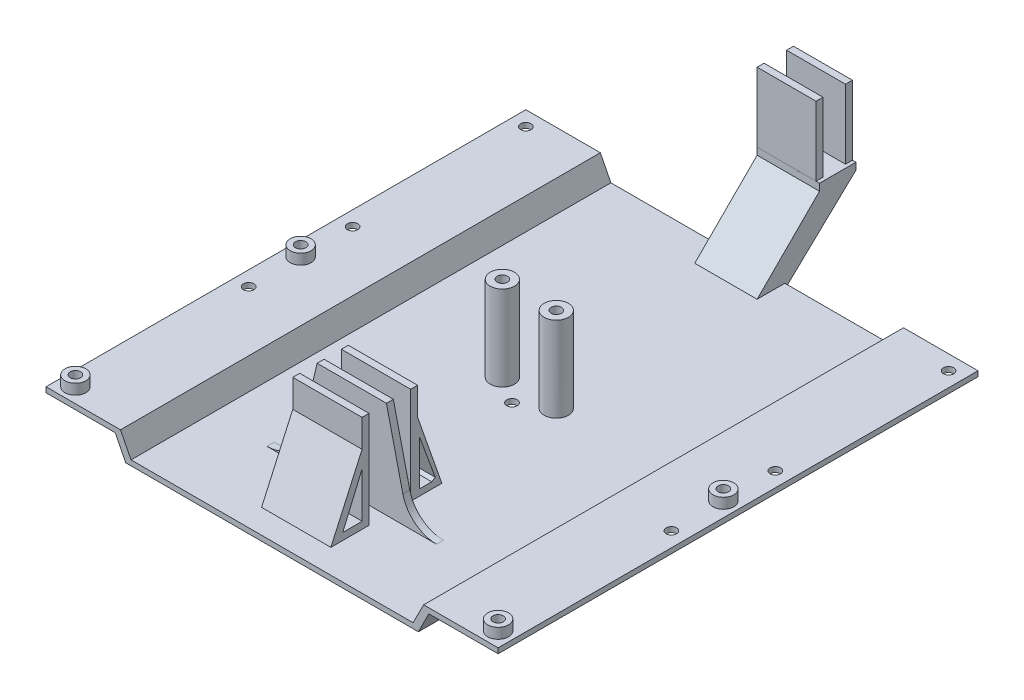
from build123d import *

# Parameters (mm, degrees)
SKETCH1_W              = 130.485281374
SKETCH1_H              = 138.485281374
SKETCH1_R              = 1.5
BOSS_EXTRUDE1_DEPTH    = 1.5
CUT_EXTRUDE1_DEPTH     = 17.5
BOSS_EXTRUDE2_DEPTH    = 138.485281
SKETCH14_R             = 3
SKETCH14_R_2           = 1.5
BOSS_EXTRUDE7_DEPTH    = 3
SKETCH15_R             = 1.5
CUT_EXTRUDE6_DEPTH     = 3
SKETCH16_R             = 3
SKETCH16_R_2           = 1.5
BOSS_EXTRUDE8_DEPTH    = 3
SKETCH17_R             = 1.5
CUT_EXTRUDE7_DEPTH     = 3
SKETCH18_R             = 3.5
SKETCH18_R_2           = 1.5
BOSS_EXTRUDE9_DEPTH    = 24.5
SKETCH19_W             = 20
SKETCH19_H             = 2
BOSS_EXTRUDE10_DEPTH   = 28
BOSS_EXTRUDE11_DEPTH   = 20
SKETCH24_R             = 1.5
CUT_EXTRUDE9_DEPTH     = 16
BOSS_EXTRUDE13_DEPTH   = 40
SKETCH27_W             = 17
SKETCH27_H             = 2
BOSS_EXTRUDE13_2_DEPTH = 40
SKETCH28_W             = 29.536458096
SKETCH28_H             = 15.843310856
CUT_EXTRUDE10_DEPTH    = 20
BOSS_EXTRUDE14_DEPTH   = 18
CUT_EXTRUDE11_DEPTH    = 26
BOSS_EXTRUDE15_DEPTH   = 2
FILLET1_R              = 10
SKETCH33_W             = 20
SKETCH33_H             = 2
BOSS_EXTRUDE16_DEPTH   = 28
BOSS_EXTRUDE17_DEPTH   = 20
CUT_EXTRUDE12_DEPTH    = 20


with BuildPart() as part:
    # Sketch1 → Boss-Extrude1 (new body)
    with BuildSketch(Plane(origin=(0, 0, 0), x_dir=(1, 0, 0), z_dir=(0, 1, 0))):
        with Locations((61, -65)):
            Rectangle(SKETCH1_W, SKETCH1_H)
        Circle(SKETCH1_R, mode=Mode.SUBTRACT)
        with Locations((122, 0)):
            Circle(SKETCH1_R, mode=Mode.SUBTRACT)
        with Locations((0, -130)):
            Circle(SKETCH1_R, mode=Mode.SUBTRACT)
        with Locations((122, -130)):
            Circle(SKETCH1_R, mode=Mode.SUBTRACT)
    extrude(amount=BOSS_EXTRUDE1_DEPTH)

    # Sketch3 → Cut-Extrude1 (cut)
    with BuildSketch(Plane(origin=(0, 1.5, 0), x_dir=(1, 0, 0), z_dir=(0, 1, 0))):
        Polygon((15.757359313, -65), (15.757359313, 4.242640687), (106.242640687, 4.242640687), (106.242640687, -65), (106.242640687, -134.242640687), (15.757359313, -134.242640687), align=None)
    extrude(amount=-CUT_EXTRUDE1_DEPTH, mode=Mode.SUBTRACT)

    # Sketch4 → Boss-Extrude2 (add, through all)
    with BuildSketch(Plane.XY.offset(134.242640687)):
        Polygon((15.757359313, 0), (18.757359313, -6), (103.242640687, -6), (106.242640687, 0), (106.242640687, 1.5), (104.742640687, 1.5), (101.703883411, -4.5), (83.627274603, -4.5), (38.372725397, -4.5), (20.296116589, -4.5), (17.257359313, 1.5), (15.757359313, 1.5), align=None)
    extrude(amount=-BOSS_EXTRUDE2_DEPTH)

    # Sketch14 → Boss-Extrude7 (add)
    with BuildSketch(Plane(origin=(0, 1.5, 0), x_dir=(1, 0, 0), z_dir=(0, 1, 0))):
        with Locations((0, -130)):
            Circle(SKETCH14_R)
        with Locations((0, -130)):
            Circle(SKETCH14_R_2, mode=Mode.SUBTRACT)
        with Locations((122, -130)):
            Circle(SKETCH14_R)
        with Locations((122, -130)):
            Circle(SKETCH14_R_2, mode=Mode.SUBTRACT)
    extrude(amount=BOSS_EXTRUDE7_DEPTH)

    # Sketch15 → Cut-Extrude6 (cut)
    with BuildSketch(Plane(origin=(0, 1.5, 0), x_dir=(1, 0, 0), z_dir=(0, 1, 0))):
        with Locations((0, -65)):
            Circle(SKETCH15_R)
        with Locations((122, -65)):
            Circle(SKETCH15_R)
    extrude(amount=-CUT_EXTRUDE6_DEPTH, mode=Mode.SUBTRACT)

    # Sketch16 → Boss-Extrude8 (add)
    with BuildSketch(Plane(origin=(0, 1.5, 0), x_dir=(1, 0, 0), z_dir=(0, 1, 0))):
        with Locations((0, -65)):
            Circle(SKETCH16_R)
        with Locations((0, -65)):
            Circle(SKETCH16_R_2, mode=Mode.SUBTRACT)
        with Locations((122, -65)):
            Circle(SKETCH16_R)
        with Locations((122, -65)):
            Circle(SKETCH16_R_2, mode=Mode.SUBTRACT)
    extrude(amount=BOSS_EXTRUDE8_DEPTH)

    # Sketch17 → Cut-Extrude7 (cut)
    with BuildSketch(Plane(origin=(0, 1.5, 0), x_dir=(1, 0, 0), z_dir=(0, 1, 0))):
        with Locations((0, -50)):
            Circle(SKETCH17_R)
        with Locations((0, -80)):
            Circle(SKETCH17_R)
        with Locations((122, -80)):
            Circle(SKETCH17_R)
        with Locations((122, -50)):
            Circle(SKETCH17_R)
    extrude(amount=-CUT_EXTRUDE7_DEPTH, mode=Mode.SUBTRACT)

    # Sketch18 → Boss-Extrude9 (add)
    with BuildSketch(Plane(origin=(0, -4.5, 0), x_dir=(1, 0, 0), z_dir=(0, 1, 0))):
        with Locations((53.22, -60)):
            Circle(SKETCH18_R)
        with Locations((53.22, -60)):
            Circle(SKETCH18_R_2, mode=Mode.SUBTRACT)
        with Locations((68.78, -60)):
            Circle(SKETCH18_R)
        with Locations((68.78, -60)):
            Circle(SKETCH18_R_2, mode=Mode.SUBTRACT)
    extrude(amount=BOSS_EXTRUDE9_DEPTH)

    # Sketch19 → Boss-Extrude10 (add)
    with BuildSketch(Plane(origin=(0, -4.5, 0), x_dir=(1, 0, 0), z_dir=(0, 1, 0))):
        with Locations((61, -110.242640687)):
            Rectangle(SKETCH19_W, SKETCH19_H)
        with Locations((61, -103.242640687)):
            Rectangle(SKETCH19_W, SKETCH19_H)
    extrude(amount=BOSS_EXTRUDE10_DEPTH)

    # Sketch20 → Boss-Extrude11 (add)
    with BuildSketch(Plane(origin=(71, 0, 0), x_dir=(0, 0, -1), z_dir=(1, 0, 0))):
        Polygon((-111.242640687, -4.5), (-118.242640687, -4.5), (-111.242640687, 15.5), align=None)
        Polygon((-115.329396397, -2.668636481), (-111.803828851, -2.668636481), (-111.803828851, 10.297263435), (-116.337361542, -2.040762337), align=None, mode=Mode.SUBTRACT)
        Polygon((-95.242640687, -4.5), (-102.242640687, 15.5), (-102.242640687, -4.5), align=None)
        Polygon((-101.681452524, 10.297263435), (-97.147919832, -2.040762337), (-98.155884977, -2.668636481), (-101.681452524, -2.668636481), align=None, mode=Mode.SUBTRACT)
    extrude(amount=-BOSS_EXTRUDE11_DEPTH)

    # Sketch24 → Cut-Extrude9 (cut)
    with BuildSketch(Plane(origin=(0, -4.5, 0), x_dir=(1, 0, 0), z_dir=(0, 1, 0))):
        with Locations((61, -65)):
            Circle(SKETCH24_R)
    extrude(amount=-CUT_EXTRUDE9_DEPTH, mode=Mode.SUBTRACT)



with BuildPart() as body_2:
    # Sketch27 → Boss-Extrude13 (new body)
    with BuildSketch(Plane(origin=(0, -4.5, 0), x_dir=(1, 0, 0), z_dir=(0, 1, 0))):
        Polygon((52.5, 14.242640687), (61, 14.242640687), (69.5, 14.242640687), (69.5, 16.242640687), (52.5, 16.242640687), align=None)
    extrude(amount=BOSS_EXTRUDE13_DEPTH)


with BuildPart() as body_3:
    # Sketch27 → Boss-Extrude13 2 (new body)
    with BuildSketch(Plane(origin=(0, -4.5, 0), x_dir=(1, 0, 0), z_dir=(0, 1, 0))):
        with Locations((61, 23.742640687)):
            Rectangle(SKETCH27_W, SKETCH27_H)
    extrude(amount=BOSS_EXTRUDE13_2_DEPTH)


with BuildPart() as cut_extrude10_tool:
    # Sketch28 → Cut-Extrude10 (new body)
    with BuildSketch(Plane.XZ.offset(4.5)):
        with Locations((60.962328077, -18.662784731)):
            Rectangle(SKETCH28_W, SKETCH28_H)
    extrude(amount=-CUT_EXTRUDE10_DEPTH)


with BuildPart() as body_2_1:
    add(body_2.part)

    # Cut-Extrude10: cut by cut_extrude10_tool
    add(cut_extrude10_tool.part, mode=Mode.SUBTRACT)


with BuildPart() as body_3_1:
    add(body_3.part)

    # Cut-Extrude10: cut by cut_extrude10_tool
    add(cut_extrude10_tool.part, mode=Mode.SUBTRACT)


with BuildPart() as part_1:
    add(part.part)

    add(body_2_1.part)  # Boss-Extrude14 merges body 2

    add(body_3_1.part)  # Boss-Extrude14 merges body 3
    # Sketch29 → Boss-Extrude14 (add)
    with BuildSketch(Plane.ZY.offset(-52.5)):
        Polygon((-24.742640687, 13.5), (-4.242640687, -6), (4.73835691, -5.480059004), (-14.241702094, 13.5), (-14.241702094, 15.5), (-24.742640687, 15.5), align=None)
    extrude(amount=-BOSS_EXTRUDE14_DEPTH)

    # Sketch30 → Cut-Extrude11 (cut)
    with BuildSketch(Plane.ZY.offset(-51)):
        Polygon((111.242640687, 15.5), (111.242640687, -4.5), (118.242640687, -4.5), align=None)
    extrude(amount=-CUT_EXTRUDE11_DEPTH, mode=Mode.SUBTRACT)

    # Sketch32 → Boss-Extrude15 (add)
    with BuildSketch(Plane.XY.offset(111.242640687)):
        Polygon((71, 23.5), (77.545089148, -4.5), (71, -4.5), align=None)
        Polygon((51, -4.5), (51, 23.5), (44.454910852, -4.5), align=None)
    extrude(amount=-BOSS_EXTRUDE15_DEPTH)

    # Fillet1
    fillet1_edges = [part_1.edges().sort_by_distance(p)[0] for p in [
        (77.545089148, -4.5, 110.242640687),
        (44.454910852, -4.5, 110.242640687),
    ]]
    fillet(fillet1_edges, radius=FILLET1_R)

    # Sketch33 → Boss-Extrude16 (add)
    with BuildSketch(Plane(origin=(0, -4.5, 0), x_dir=(1, 0, 0), z_dir=(0, 1, 0))):
        with Locations((61, -117.27180301)):
            Rectangle(SKETCH33_W, SKETCH33_H)
    extrude(amount=BOSS_EXTRUDE16_DEPTH)

    # Sketch34 → Boss-Extrude17 (add)
    with BuildSketch(Plane(origin=(71, 0, 0), x_dir=(0, 0, -1), z_dir=(1, 0, 0))):
        Polygon((-118.27180301, -4.5), (-118.27180301, 15.5), (-127.27180301, -4.5), align=None)
    extrude(amount=-BOSS_EXTRUDE17_DEPTH)

    # Sketch35 → Cut-Extrude12 (cut)
    with BuildSketch(Plane(origin=(71, 0, 0), x_dir=(0, 0, -1), z_dir=(1, 0, 0))):
        Polygon((-121.77180301, -2.5), (-118.236471352, -2.5), (-118.236471352, 10.68955001), (-123.840420038, -2.5), align=None)
    extrude(amount=-CUT_EXTRUDE12_DEPTH, mode=Mode.SUBTRACT)


solid = part_1.part
